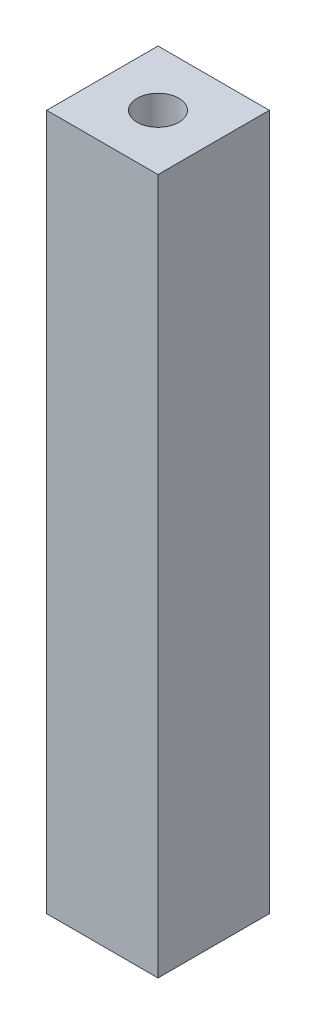
from build123d import *

# Parameters (mm, degrees)
SKETCH1_W           = 8
SKETCH1_H           = 8
BOSS_EXTRUDE1_DEPTH = 50
SKETCH2_R           = 1.5
CUT_EXTRUDE1_DEPTH  = 51


with BuildPart() as part:
    # Sketch1 → Boss-Extrude1 (new body)
    with BuildSketch(Plane(origin=(0, 0, 0), x_dir=(1, 0, 0), z_dir=(0, 1, 0))):
        Rectangle(SKETCH1_W, SKETCH1_H)
    extrude(amount=BOSS_EXTRUDE1_DEPTH)

    # Sketch2 → Cut-Extrude1 (cut, through all)
    with BuildSketch(Plane(origin=(0, 50, 0), x_dir=(1, 0, 0), z_dir=(0, 1, 0))):
        Circle(SKETCH2_R)
    extrude(amount=-CUT_EXTRUDE1_DEPTH, mode=Mode.SUBTRACT)


solid = part.part
